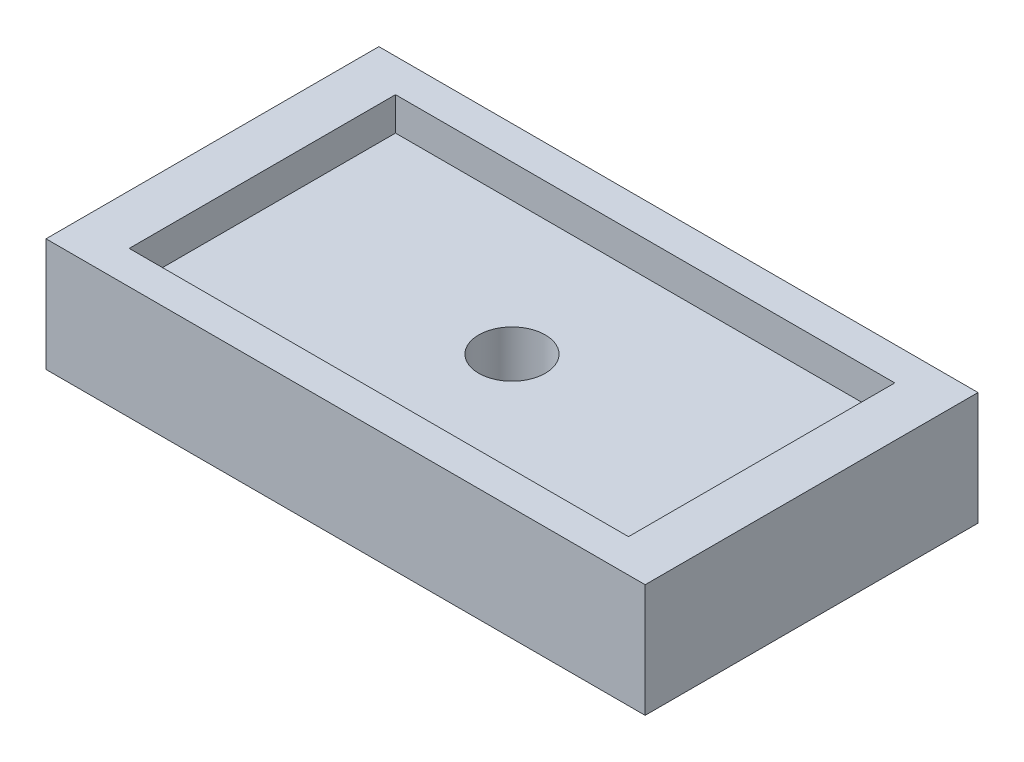
from build123d import *

# Parameters (mm, degrees)
SKETCH1_W           = 90
SKETCH1_H           = 50
BOSS_EXTRUDE1_DEPTH = 17
SKETCH2_W           = 75
SKETCH2_H           = 40
CUT_EXTRUDE1_DEPTH  = 5
SKETCH3_R           = 5
CUT_EXTRUDE2_DEPTH  = 13


with BuildPart() as part:
    # Sketch1 → Boss-Extrude1 (new body)
    with BuildSketch(Plane(origin=(0, 0, 0), x_dir=(1, 0, 0), z_dir=(0, 1, 0))):
        with Locations((45, 25)):
            Rectangle(SKETCH1_W, SKETCH1_H)
    extrude(amount=BOSS_EXTRUDE1_DEPTH)

    # Sketch2 → Cut-Extrude1 (cut)
    with BuildSketch(Plane(origin=(0, 17, 0), x_dir=(1, 0, 0), z_dir=(0, 1, 0))):
        with Locations((45, 25)):
            Rectangle(SKETCH2_W, SKETCH2_H)
    extrude(amount=-CUT_EXTRUDE1_DEPTH, mode=Mode.SUBTRACT)

    # Sketch3 → Cut-Extrude2 (cut, through all)
    with BuildSketch(Plane(origin=(0, 12, 0), x_dir=(1, 0, 0), z_dir=(0, 1, 0))):
        with Locations((45, 25)):
            Circle(SKETCH3_R)
    extrude(amount=-CUT_EXTRUDE2_DEPTH, mode=Mode.SUBTRACT)


solid = part.part
